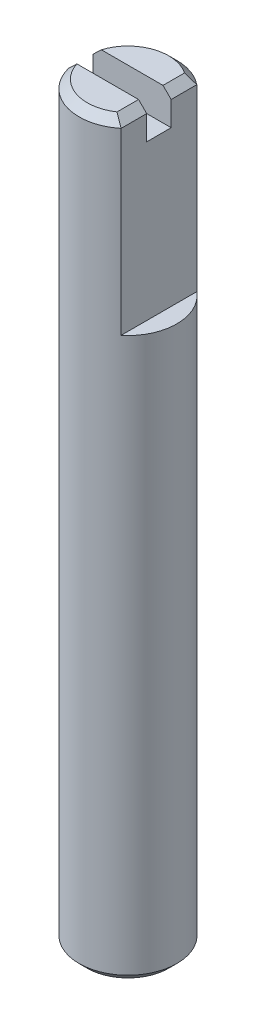
from build123d import *

# Parameters (mm, degrees)
SKIZZE1_R                       = 3
AUFSATZ_LINEAR_AUSTRAGEN1_DEPTH = 46
SKIZZE2_W                       = 2.221209883
SKIZZE2_H                       = 8.751437557
SCHNITT_LINEAR_AUSTRAGEN1_DEPTH = 11.5
FASE1_SIZE                      = 0.5
SCHNITT_LINEAR_AUSTRAGEN2_DEPTH = 2


with BuildPart() as part:
    # Skizze1 → Aufsatz-Linear austragen1 (new body)
    with BuildSketch(Plane(origin=(0, 0, 0), x_dir=(1, 0, 0), z_dir=(0, 1, 0))):
        Circle(SKIZZE1_R)
    extrude(amount=AUFSATZ_LINEAR_AUSTRAGEN1_DEPTH)

    # Skizze2 → Schnitt-Linear austragen1 (cut)
    with BuildSketch(Plane(origin=(0, 46, 0), x_dir=(1, 0, 0), z_dir=(0, 1, 0))):
        with Locations((3.010604942, -0.571236499)):
            Rectangle(SKIZZE2_W, SKIZZE2_H)
    extrude(amount=-SCHNITT_LINEAR_AUSTRAGEN1_DEPTH, mode=Mode.SUBTRACT)

    # Fase1
    fase1_edges = [part.edges().sort_by_distance(p)[0] for p in [
        (-3, 0, 0),
        (-3, 46, 0),
        (1.9, 46, 0),
    ]]
    chamfer(fase1_edges, length=FASE1_SIZE)

    # Skizze3 → Schnitt-Linear austragen2 (cut)
    with BuildSketch(Plane(origin=(0, 46, 0), x_dir=(1, 0, 0), z_dir=(0, 1, 0))):
        Polygon((-4.20448111, 0.75), (0.75, 0.75), (4.606648868, 0.75), (4.606648868, -0.75), (0.75, -0.75), (-4.20448111, -0.75), align=None)
    extrude(amount=-SCHNITT_LINEAR_AUSTRAGEN2_DEPTH, mode=Mode.SUBTRACT)


solid = part.part
